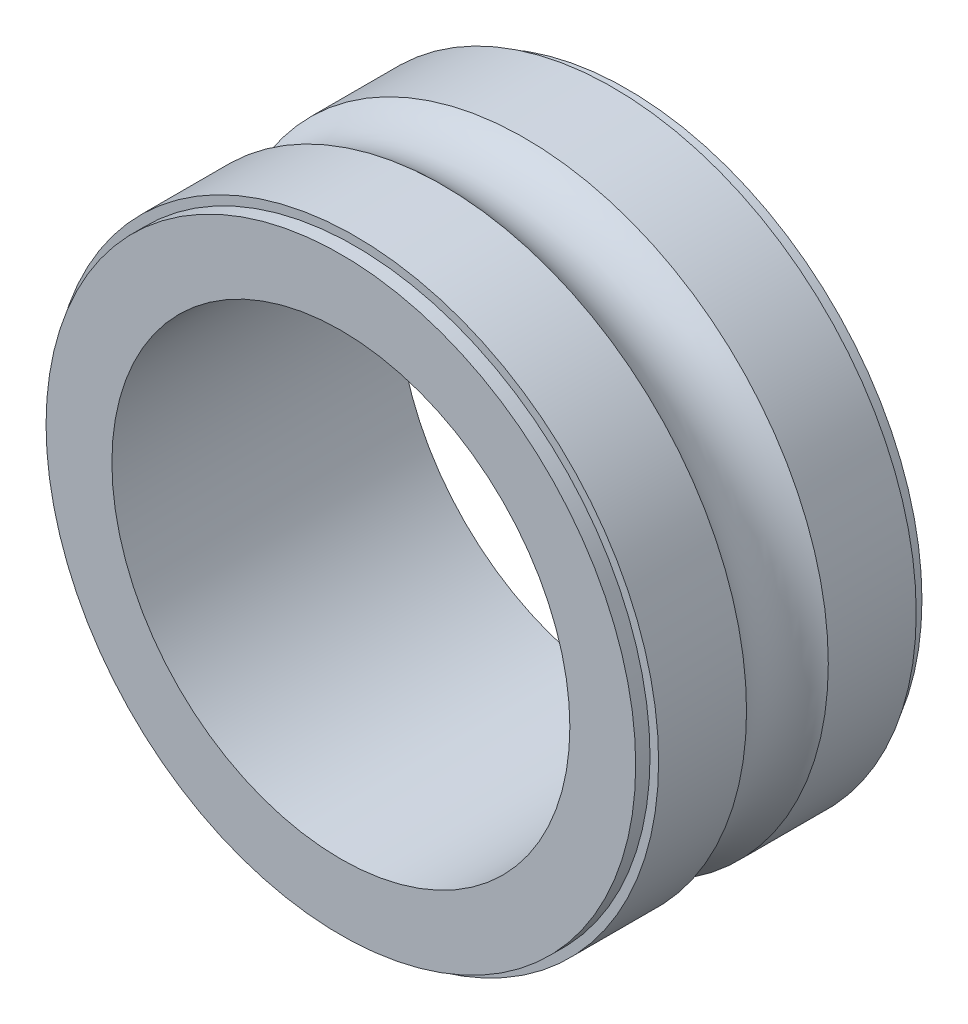
from build123d import *


with BuildPart() as part:
    # Sketch1 → Revolve1 (revolve)
    with BuildSketch(Plane(origin=(0, 0, 0), x_dir=(0, 0, -1), z_dir=(1, 0, 0))):
        with BuildLine():
            Line((-2.5, 5.15), (-2.5, 4))
            Line((-2.5, 4), (2.5, 4))
            Line((2.5, 4), (2.5, 5.15))
            Line((2.5, 5.15), (2.25, 5.15))
            Line((2.25, 5.15), (2.25, 5.3))
            Line((2.25, 5.3), (0.714142843, 5.3))
            ThreePointArc((0.714142843, 5.3), (0, 5), (-0.714142843, 5.3))
            Line((-0.714142843, 5.3), (-2.25, 5.3))
            Line((-2.25, 5.3), (-2.25, 5.15))
            Line((-2.25, 5.15), (-2.5, 5.15))
        make_face()
    revolve(axis=Axis((0, 0, 6.755399071), (0, 0, -1)))


solid = part.part
